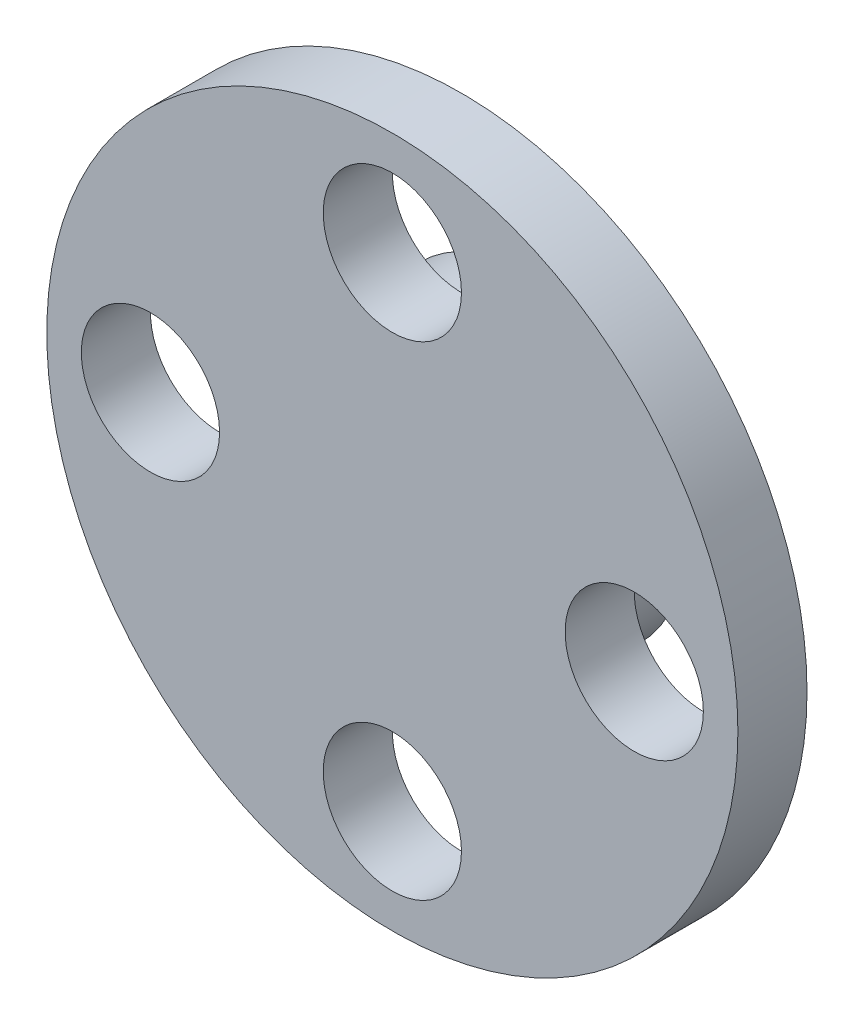
from build123d import *

# Parameters (mm, degrees)
SKETCH1_R           = 10
SKETCH1_R_2         = 2
BOSS_EXTRUDE1_DEPTH = 2
SKETCH2_R           = 4.5
SKETCH2_R_2         = 3.5
BOSS_EXTRUDE2_DEPTH = 2


with BuildPart() as part:
    # Sketch1 → Boss-Extrude1 (new body)
    with BuildSketch(Plane.XY):
        Circle(SKETCH1_R)
        with Locations((7, 0)):
            Circle(SKETCH1_R_2, mode=Mode.SUBTRACT)
        with Locations((0, 7)):
            Circle(SKETCH1_R_2, mode=Mode.SUBTRACT)
        with Locations((-7, 0)):
            Circle(SKETCH1_R_2, mode=Mode.SUBTRACT)
        with Locations((0, -7)):
            Circle(SKETCH1_R_2, mode=Mode.SUBTRACT)
    extrude(amount=BOSS_EXTRUDE1_DEPTH)

    # Sketch2 → Boss-Extrude2 (add)
    with BuildSketch(Plane(origin=(0, 0, 0), x_dir=(-1, 0, 0), z_dir=(0, 0, -1))):
        Circle(SKETCH2_R)
        Circle(SKETCH2_R_2, mode=Mode.SUBTRACT)
    extrude(amount=BOSS_EXTRUDE2_DEPTH)


solid = part.part
